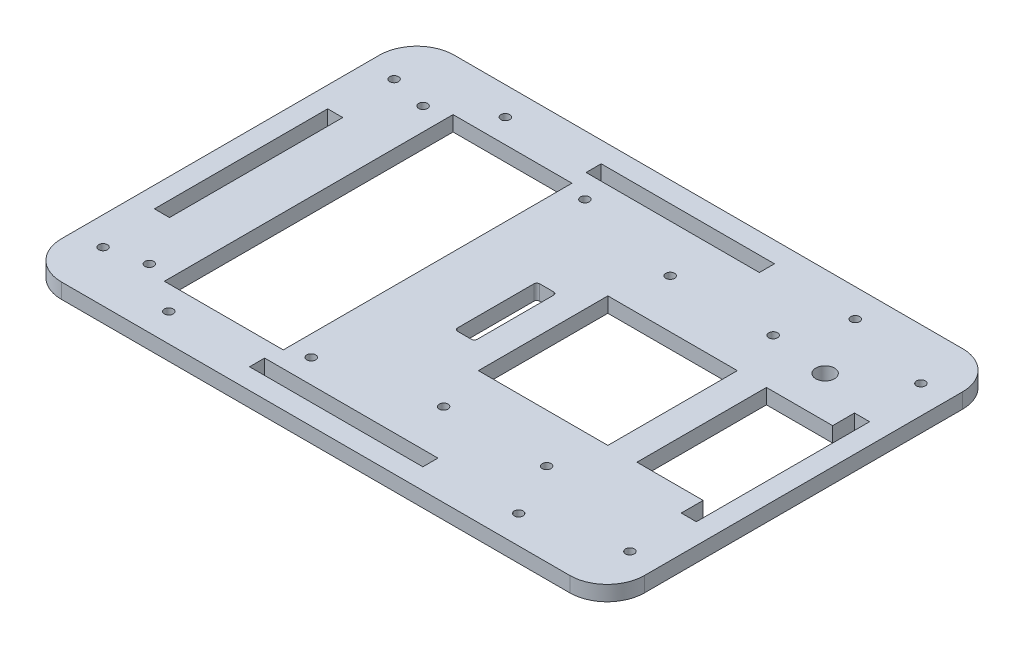
from build123d import *

# Parameters (mm, degrees)
MAIN_DEPTH                         = 5.13
ASSEMBLY_SLOTS_REACH               = 7.13
SKETCH2_R                          = 1.5
SKETCH2_W                          = 5.13
SKETCH2_H                          = 58.88
SKETCH2_W_2                        = 58.88
SKETCH2_H_2                        = 5.13
LCD_AND_BLOCK_SLOT_REACH           = 7.13
SKETCH3_W                          = 40.4
SKETCH3_H                          = 98.1
SKETCH3_W_2                        = 44
SKETCH3_H_2                        = 44
LCD_SCREWHOLES_D                   = 3
LCD_SCREWHOLES_DEPTH               = 25.4
LCD_SCREWHOLES_TIP                 = 0.901290929
CORE_SCREWHOLES_PATTERN_COUNT      = 2
CORE_SCREWHOLES_PATTERN_PITCH      = 35
CORE_SCREWHOLES_PATTERN_COUNT_DIR2 = 2
CORE_SCREWHOLES_PATTERN_PITCH_DIR2 = 77
HINGE_SLOT_REACH                   = 7.13
SKETCH11_W                         = 22.5
SKETCH11_H                         = 44
LATCH_SLOT_REACH                   = 7.13
LID_THERMISTOR_HOLE_D              = 6.35
LID_THERMISTOR_HOLE_DEPTH          = 7.6
LID_THERMISTOR_HOLE_TIP            = 1.907732465


with BuildPart() as part:
    # Sketch1 → Main (new body)
    with BuildSketch(Plane(origin=(0, 0, 0), x_dir=(1, 0, 0), z_dir=(0, 1, 0))):
        with BuildLine():
            Line((-55.207201859, 101.249932113), (117.542798141, 101.249932113))
            ThreePointArc((117.542798141, 101.249932113), (126.523054262, 97.530188234), (130.242798141, 88.549932113))
            Line((130.242798141, 88.549932113), (130.242798141, -19.530067887))
            ThreePointArc((130.242798141, -19.530067887), (126.523054262, -28.510324008), (117.542798141, -32.230067887))
            Line((117.542798141, -32.230067887), (-55.207201859, -32.230067887))
            ThreePointArc((-55.207201859, -32.230067887), (-64.18745798, -28.510324008), (-67.907201859, -19.530067887))
            Line((-67.907201859, -19.530067887), (-67.907201859, 88.549932113))
            ThreePointArc((-67.907201859, 88.549932113), (-64.18745798, 97.530188234), (-55.207201859, 101.249932113))
        make_face()
    extrude(amount=MAIN_DEPTH)

    # Sketch2 → Assembly slots (cut, up to next)
    with BuildSketch(Plane(origin=(0, 5.13, 0), x_dir=(1, 0, 0), z_dir=(0, 1, 0)), mode=Mode.PRIVATE) as assembly_slots_sk1:
        with Locations((-28.272201859, 91.689932113)):
            Circle(SKETCH2_R)
    assembly_slots_tool1 = extrude(assembly_slots_sk1.sketch, amount=-ASSEMBLY_SLOTS_REACH, mode=Mode.PRIVATE) & part.part
    add(assembly_slots_tool1.solids().sort_by_distance((-28.272202, 5.13, -91.689932))[0], mode=Mode.SUBTRACT)
    # Sketch2 → Assembly slots (cut, up to next)
    with BuildSketch(Plane(origin=(0, 5.13, 0), x_dir=(1, 0, 0), z_dir=(0, 1, 0)), mode=Mode.PRIVATE) as assembly_slots_sk2:
        with Locations((90.607798141, 91.689932113)):
            Circle(SKETCH2_R)
    assembly_slots_tool2 = extrude(assembly_slots_sk2.sketch, amount=-ASSEMBLY_SLOTS_REACH, mode=Mode.PRIVATE) & part.part
    add(assembly_slots_tool2.solids().sort_by_distance((90.607798, 5.13, -91.689932))[0], mode=Mode.SUBTRACT)
    # Sketch2 → Assembly slots (cut, up to next)
    with BuildSketch(Plane(origin=(0, 5.13, 0), x_dir=(1, 0, 0), z_dir=(0, 1, 0)), mode=Mode.PRIVATE) as assembly_slots_sk3:
        with Locations((-58.347201859, -14.930067887)):
            Circle(SKETCH2_R)
    assembly_slots_tool3 = extrude(assembly_slots_sk3.sketch, amount=-ASSEMBLY_SLOTS_REACH, mode=Mode.PRIVATE) & part.part
    add(assembly_slots_tool3.solids().sort_by_distance((-58.347202, 5.13, 14.930068))[0], mode=Mode.SUBTRACT)
    # Sketch2 → Assembly slots (cut, up to next)
    with BuildSketch(Plane(origin=(0, 5.13, 0), x_dir=(1, 0, 0), z_dir=(0, 1, 0)), mode=Mode.PRIVATE) as assembly_slots_sk4:
        with Locations((-58.347201859, 83.949932113)):
            Circle(SKETCH2_R)
    assembly_slots_tool4 = extrude(assembly_slots_sk4.sketch, amount=-ASSEMBLY_SLOTS_REACH, mode=Mode.PRIVATE) & part.part
    add(assembly_slots_tool4.solids().sort_by_distance((-58.347202, 5.13, -83.949932))[0], mode=Mode.SUBTRACT)
    # Sketch2 → Assembly slots (cut, up to next)
    with BuildSketch(Plane(origin=(0, 5.13, 0), x_dir=(1, 0, 0), z_dir=(0, 1, 0)), mode=Mode.PRIVATE) as assembly_slots_sk5:
        with Locations((120.682798141, 83.949932113)):
            Circle(SKETCH2_R)
    assembly_slots_tool5 = extrude(assembly_slots_sk5.sketch, amount=-ASSEMBLY_SLOTS_REACH, mode=Mode.PRIVATE) & part.part
    add(assembly_slots_tool5.solids().sort_by_distance((120.682798, 5.13, -83.949932))[0], mode=Mode.SUBTRACT)
    # Sketch2 → Assembly slots (cut, up to next)
    with BuildSketch(Plane(origin=(0, 5.13, 0), x_dir=(1, 0, 0), z_dir=(0, 1, 0)), mode=Mode.PRIVATE) as assembly_slots_sk6:
        with Locations((120.682798141, -14.930067887)):
            Circle(SKETCH2_R)
    assembly_slots_tool6 = extrude(assembly_slots_sk6.sketch, amount=-ASSEMBLY_SLOTS_REACH, mode=Mode.PRIVATE) & part.part
    add(assembly_slots_tool6.solids().sort_by_distance((120.682798, 5.13, 14.930068))[0], mode=Mode.SUBTRACT)
    # Sketch2 → Assembly slots (cut, up to next)
    with BuildSketch(Plane(origin=(0, 5.13, 0), x_dir=(1, 0, 0), z_dir=(0, 1, 0)), mode=Mode.PRIVATE) as assembly_slots_sk7:
        with Locations((90.607798141, -22.670067887)):
            Circle(SKETCH2_R)
    assembly_slots_tool7 = extrude(assembly_slots_sk7.sketch, amount=-ASSEMBLY_SLOTS_REACH, mode=Mode.PRIVATE) & part.part
    add(assembly_slots_tool7.solids().sort_by_distance((90.607798, 5.13, 22.670068))[0], mode=Mode.SUBTRACT)
    # Sketch2 → Assembly slots (cut, up to next)
    with BuildSketch(Plane(origin=(0, 5.13, 0), x_dir=(1, 0, 0), z_dir=(0, 1, 0)), mode=Mode.PRIVATE) as assembly_slots_sk8:
        with Locations((-28.272201859, -22.670067887)):
            Circle(SKETCH2_R)
    assembly_slots_tool8 = extrude(assembly_slots_sk8.sketch, amount=-ASSEMBLY_SLOTS_REACH, mode=Mode.PRIVATE) & part.part
    add(assembly_slots_tool8.solids().sort_by_distance((-28.272202, 5.13, 22.670068))[0], mode=Mode.SUBTRACT)
    # Sketch2 → Assembly slots (cut, up to next)
    with BuildSketch(Plane(origin=(0, 5.13, 0), x_dir=(1, 0, 0), z_dir=(0, 1, 0)), mode=Mode.PRIVATE) as assembly_slots_sk9:
        with Locations((-58.342201859, 34.509932113)):
            Rectangle(SKETCH2_W, SKETCH2_H)
    assembly_slots_tool9 = extrude(assembly_slots_sk9.sketch, amount=-ASSEMBLY_SLOTS_REACH, mode=Mode.PRIVATE) & part.part
    add(assembly_slots_tool9.solids().sort_by_distance((-58.342202, 5.13, -34.509932))[0], mode=Mode.SUBTRACT)
    # Sketch2 → Assembly slots (cut, up to next)
    with BuildSketch(Plane(origin=(0, 5.13, 0), x_dir=(1, 0, 0), z_dir=(0, 1, 0)), mode=Mode.PRIVATE) as assembly_slots_sk10:
        with Locations((31.167798141, 91.684932113)):
            Rectangle(SKETCH2_W_2, SKETCH2_H_2)
    assembly_slots_tool10 = extrude(assembly_slots_sk10.sketch, amount=-ASSEMBLY_SLOTS_REACH, mode=Mode.PRIVATE) & part.part
    add(assembly_slots_tool10.solids().sort_by_distance((31.167798, 5.13, -91.684932))[0], mode=Mode.SUBTRACT)
    # Sketch2 → Assembly slots (cut, up to next)
    with BuildSketch(Plane(origin=(0, 5.13, 0), x_dir=(1, 0, 0), z_dir=(0, 1, 0)), mode=Mode.PRIVATE) as assembly_slots_sk11:
        with Locations((120.677798141, 34.509932113)):
            Rectangle(SKETCH2_W, SKETCH2_H)
    assembly_slots_tool11 = extrude(assembly_slots_sk11.sketch, amount=-ASSEMBLY_SLOTS_REACH, mode=Mode.PRIVATE) & part.part
    add(assembly_slots_tool11.solids().sort_by_distance((120.677798, 5.13, -34.509932))[0], mode=Mode.SUBTRACT)
    # Sketch2 → Assembly slots (cut, up to next)
    with BuildSketch(Plane(origin=(0, 5.13, 0), x_dir=(1, 0, 0), z_dir=(0, 1, 0)), mode=Mode.PRIVATE) as assembly_slots_sk12:
        with Locations((31.167798141, -22.665067887)):
            Rectangle(SKETCH2_W_2, SKETCH2_H_2)
    assembly_slots_tool12 = extrude(assembly_slots_sk12.sketch, amount=-ASSEMBLY_SLOTS_REACH, mode=Mode.PRIVATE) & part.part
    add(assembly_slots_tool12.solids().sort_by_distance((31.167798, 5.13, 22.665068))[0], mode=Mode.SUBTRACT)

    # Sketch3 → LCD and Block slot (cut, up to next)
    with BuildSketch(Plane.XZ, mode=Mode.PRIVATE) as lcd_and_block_slot_sk1:
        with Locations((-17.707201859, -34.509932113)):
            Rectangle(SKETCH3_W, SKETCH3_H)
    lcd_and_block_slot_tool1 = extrude(lcd_and_block_slot_sk1.sketch, amount=-LCD_AND_BLOCK_SLOT_REACH, mode=Mode.PRIVATE) & part.part
    add(lcd_and_block_slot_tool1.solids().sort_by_distance((-17.707202, 0, -34.509932))[0], mode=Mode.SUBTRACT)
    # Sketch3 → LCD and Block slot (cut, up to next)
    with BuildSketch(Plane.XZ, mode=Mode.PRIVATE) as lcd_and_block_slot_sk2:
        with Locations((63.742798141, -34.509932113)):
            Rectangle(SKETCH3_W_2, SKETCH3_H_2)
    lcd_and_block_slot_tool2 = extrude(lcd_and_block_slot_sk2.sketch, amount=-LCD_AND_BLOCK_SLOT_REACH, mode=Mode.PRIVATE) & part.part
    add(lcd_and_block_slot_tool2.solids().sort_by_distance((63.742798, 0, -34.509932))[0], mode=Mode.SUBTRACT)

    # LCD screwholes
    with Locations(Plane(origin=(0, 5.13, 0), x_dir=(-1, 0, 0), z_dir=(0, 1, 0))):
        with Locations((45.557201859, 11.990067887), (-9.442798141, 11.990067887), (45.557201859, -81.009932113), (-9.442798141, -81.009932113)):
            Hole(LCD_SCREWHOLES_D / 2, depth=LCD_SCREWHOLES_DEPTH)
            with Locations((0, 0, -(LCD_SCREWHOLES_DEPTH + LCD_SCREWHOLES_TIP / 2))):  # 118° drill point
                Cone(0, LCD_SCREWHOLES_D / 2, LCD_SCREWHOLES_TIP, mode=Mode.SUBTRACT)

    # Sketch8 → Core screwholes (revolve, cut)
    with BuildSketch(Plane(origin=(46.427392408, 5.13, -73.009932113), x_dir=(0, 0, 1), z_dir=(1, 0, 0))):
        Polygon((0, 0), (0, 26.301290929), (1.5, 25.4), (1.5, 0), align=None)
    core_screwholes = revolve(axis=Axis((46.427392408, 11.48, -73.009932113), (0, -1, 0)), mode=Mode.SUBTRACT)

    # Core screwholes pattern: Core screwholes 2 × 2
    with Locations(*[(i * CORE_SCREWHOLES_PATTERN_PITCH, 0, j * CORE_SCREWHOLES_PATTERN_PITCH_DIR2) for i in range(CORE_SCREWHOLES_PATTERN_COUNT) for j in range(CORE_SCREWHOLES_PATTERN_COUNT_DIR2) if (i, j) != (0, 0)]):
        add(core_screwholes, mode=Mode.SUBTRACT)

    # Sketch11 → Hinge slot (cut, up to next)
    with BuildSketch(Plane(origin=(0, 5.13, 0), x_dir=(1, 0, 0), z_dir=(0, 1, 0)), mode=Mode.PRIVATE) as hinge_slot_sk1:
        with Locations((106.874365391, 34.509932113)):
            Rectangle(SKETCH11_W, SKETCH11_H)
    hinge_slot_tool1 = extrude(hinge_slot_sk1.sketch, amount=-HINGE_SLOT_REACH, mode=Mode.PRIVATE) & part.part
    add(hinge_slot_tool1.solids().sort_by_distance((106.874365, 5.13, -34.509932))[0], mode=Mode.SUBTRACT)

    # Sketch13 → Latch Slot (cut, up to next)
    with BuildSketch(Plane(origin=(0, 5.13, 0), x_dir=(1, 0, 0), z_dir=(0, 1, 0)), mode=Mode.PRIVATE) as latch_slot_sk1:
        with BuildLine():
            Line((26.626560662, 48.479932113), (31.326560662, 48.479932113))
            ThreePointArc((31.326560662, 48.479932113), (32.033667443, 48.187038894), (32.326560662, 47.479932113))
            Line((32.326560662, 47.479932113), (32.326560662, 21.539932113))
            ThreePointArc((32.326560662, 21.539932113), (32.033667443, 20.832825332), (31.326560662, 20.539932113))
            Line((31.326560662, 20.539932113), (26.626560662, 20.539932113))
            ThreePointArc((26.626560662, 20.539932113), (25.919453881, 20.832825332), (25.626560662, 21.539932113))
            Line((25.626560662, 21.539932113), (25.626560662, 47.479932113))
            ThreePointArc((25.626560662, 47.479932113), (25.919453881, 48.187038894), (26.626560662, 48.479932113))
        make_face()
    latch_slot_tool1 = extrude(latch_slot_sk1.sketch, amount=-LATCH_SLOT_REACH, mode=Mode.PRIVATE) & part.part
    add(latch_slot_tool1.solids().sort_by_distance((28.976561, 5.13, -34.509932))[0], mode=Mode.SUBTRACT)

    # Lid thermistor hole
    with Locations(Plane(origin=(0, 5.13, 0), x_dir=(-1, 0, 0), z_dir=(0, 1, 0))):
        with Locations((-101.47244154, -70.602615051)):
            Hole(LID_THERMISTOR_HOLE_D / 2, depth=LID_THERMISTOR_HOLE_DEPTH)
            with Locations((0, 0, -(LID_THERMISTOR_HOLE_DEPTH + LID_THERMISTOR_HOLE_TIP / 2))):  # 118° drill point
                Cone(0, LID_THERMISTOR_HOLE_D / 2, LID_THERMISTOR_HOLE_TIP, mode=Mode.SUBTRACT)


solid = part.part
